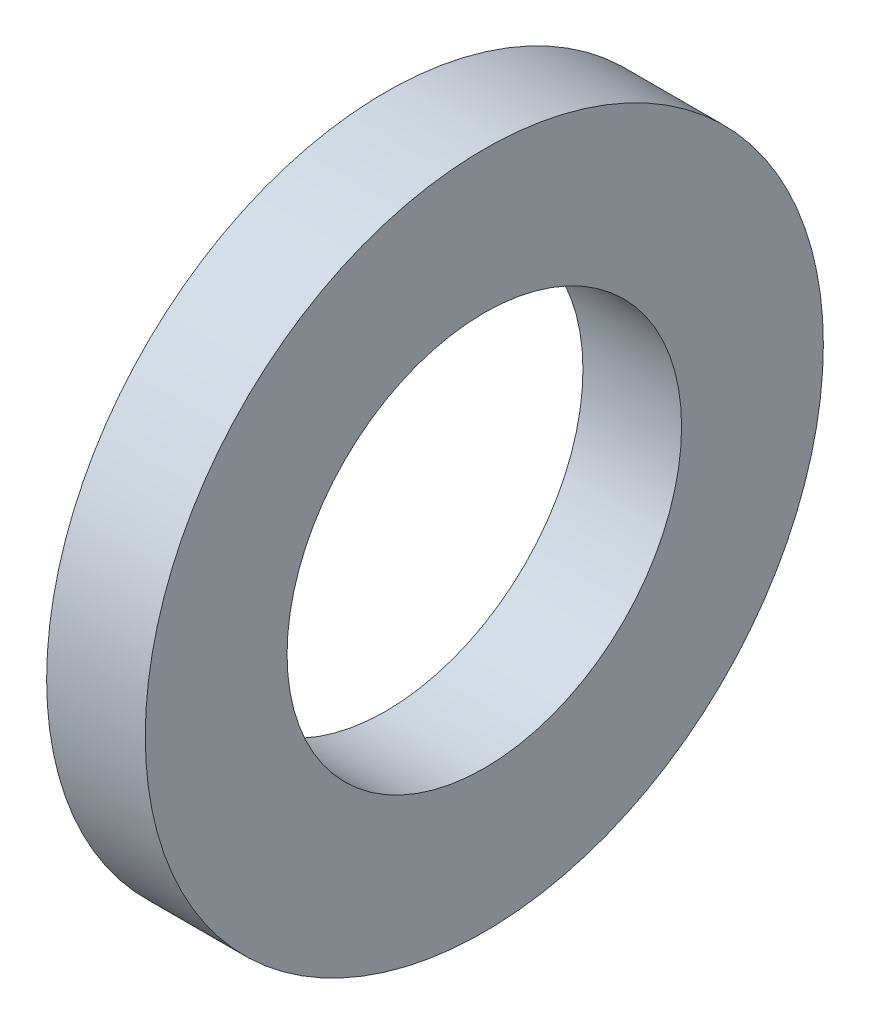
from build123d import *

# Parameters (mm, degrees)
SKETCH1_W = 1.6
SKETCH1_H = 2.3


with BuildPart() as part:
    # Sketch1 → Base-Revolve (revolve)
    with BuildSketch(Plane.XY):
        with Locations((-0.8, 4.35)):
            Rectangle(SKETCH1_W, SKETCH1_H)
    revolve(axis=Axis((-34.925, 0, 0), (1, 0, 0)))


solid = part.part
